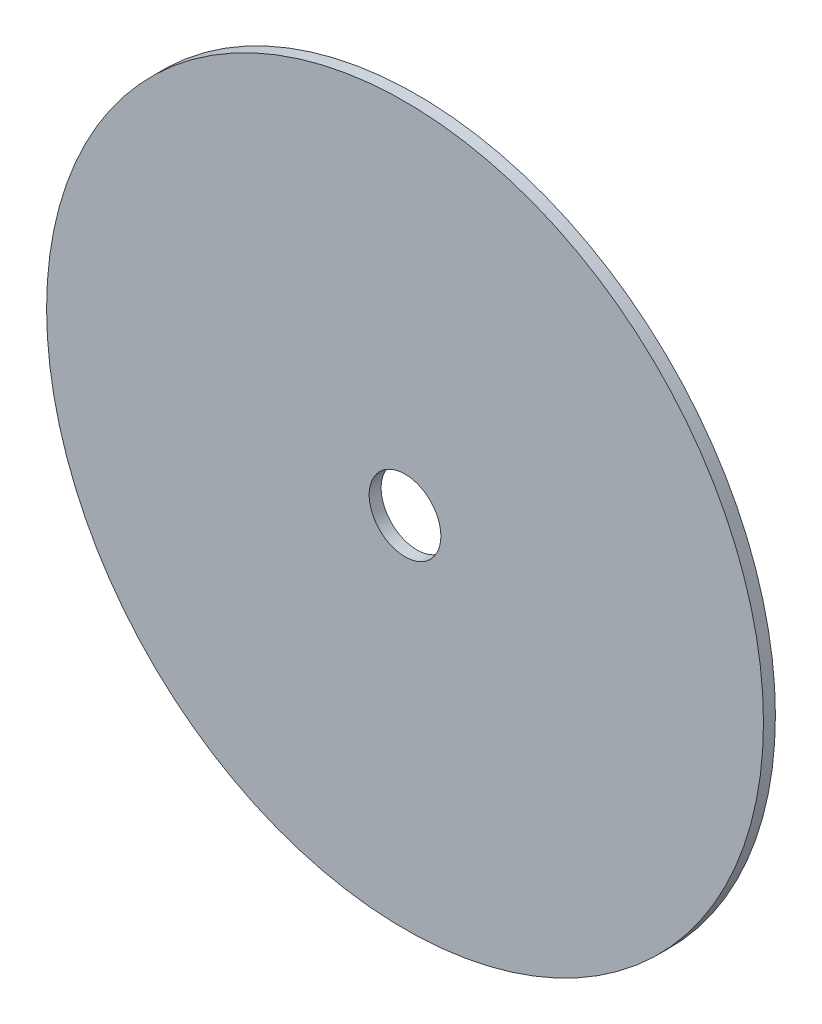
from build123d import *

# Parameters (mm, degrees)
SZKIC1_R                    = 15
SZKIC1_R_2                  = 1.5
DODANIE_WYCI_GNI_CIE1_DEPTH = 0.5


with BuildPart() as part:
    # Szkic1 → Dodanie-wyciągnięcie1 (new body)
    with BuildSketch(Plane.XY):
        Circle(SZKIC1_R)
        Circle(SZKIC1_R_2, mode=Mode.SUBTRACT)
    extrude(amount=DODANIE_WYCI_GNI_CIE1_DEPTH)


solid = part.part
